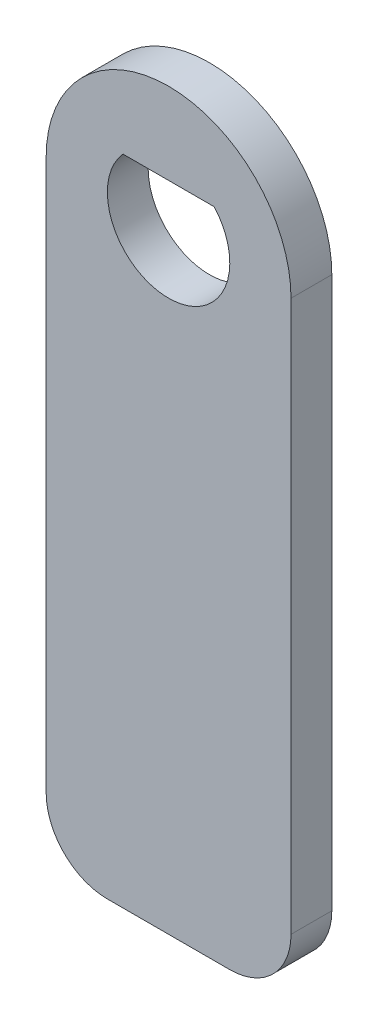
from build123d import *

# Parameters (mm, degrees)
BOSS_EXTRUDE1_DEPTH = 2


with BuildPart() as part:
    # Sketch1 → Boss-Extrude1 (new body)
    with BuildSketch(Plane.XY):
        with BuildLine():
            Line((-6, 0), (-6, -27))
            ThreePointArc((-6, -27), (-5.121320344, -29.121320344), (-3, -30))
            Line((-3, -30), (3, -30))
            ThreePointArc((3, -30), (5.121320344, -29.121320344), (6, -27))
            Line((6, -27), (6, 0))
            ThreePointArc((6, 0), (0, 6), (-6, 0))
        make_face()
        with BuildLine():
            Line((-2.236067977, 2), (2.236067977, 2))
            ThreePointArc((2.236067977, 2), (0, -3), (-2.236067977, 2))
        make_face(mode=Mode.SUBTRACT)
    extrude(amount=BOSS_EXTRUDE1_DEPTH)


solid = part.part
